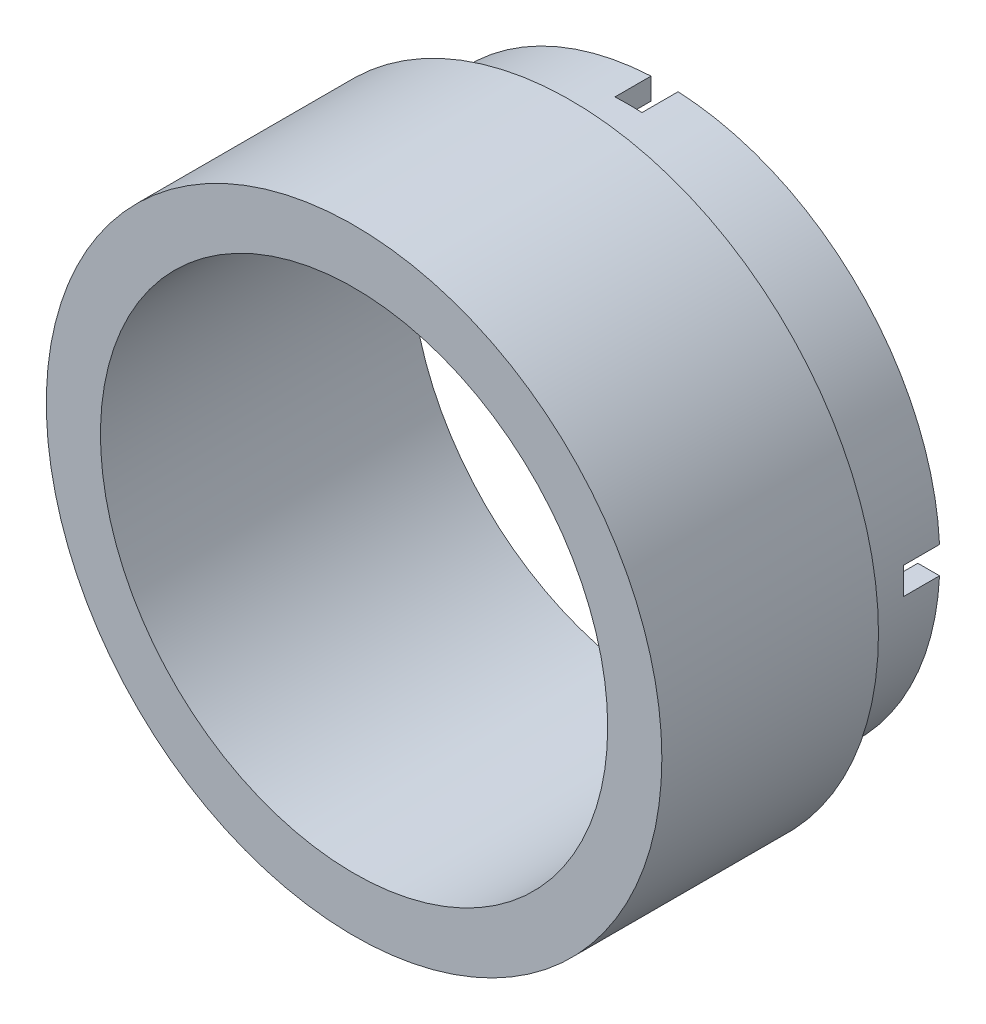
from build123d import *

# Parameters (mm, degrees)
SKETCH1_R           = 15.25
SKETCH1_R_2         = 14.05
BOSS_EXTRUDE1_DEPTH = 5.2
CUT_EXTRUDE1_DEPTH  = 2
SKETCH4_R           = 17.05
SKETCH4_R_2         = 14.05
BOSS_EXTRUDE2_DEPTH = 12


with BuildPart() as part:
    # Sketch1 → Boss-Extrude1 (new body)
    with BuildSketch(Plane.XY):
        Circle(SKETCH1_R)
        Circle(SKETCH1_R_2, mode=Mode.SUBTRACT)
    extrude(amount=BOSS_EXTRUDE1_DEPTH)

    # Sketch2 → Cut-Extrude1 (cut)
    with BuildSketch(Plane.XY):
        Polygon((-0.75, 17.451253501), (0.75, 17.451253501), (0.75, 0.75), (21.876520237, 0.75), (21.876520237, -0.75), (0.75, -0.75), (0.75, -17.451253501), (-0.75, -17.451253501), (-0.75, -0.75), (-21.876520237, -0.75), (-21.876520237, 0.75), (-0.75, 0.75), align=None)
    extrude(amount=CUT_EXTRUDE1_DEPTH, mode=Mode.SUBTRACT)

    # Sketch4 → Boss-Extrude2 (add)
    with BuildSketch(Plane.XY.offset(5.2)):
        Circle(SKETCH4_R)
        Circle(SKETCH4_R_2, mode=Mode.SUBTRACT)
    extrude(amount=BOSS_EXTRUDE2_DEPTH)


solid = part.part
